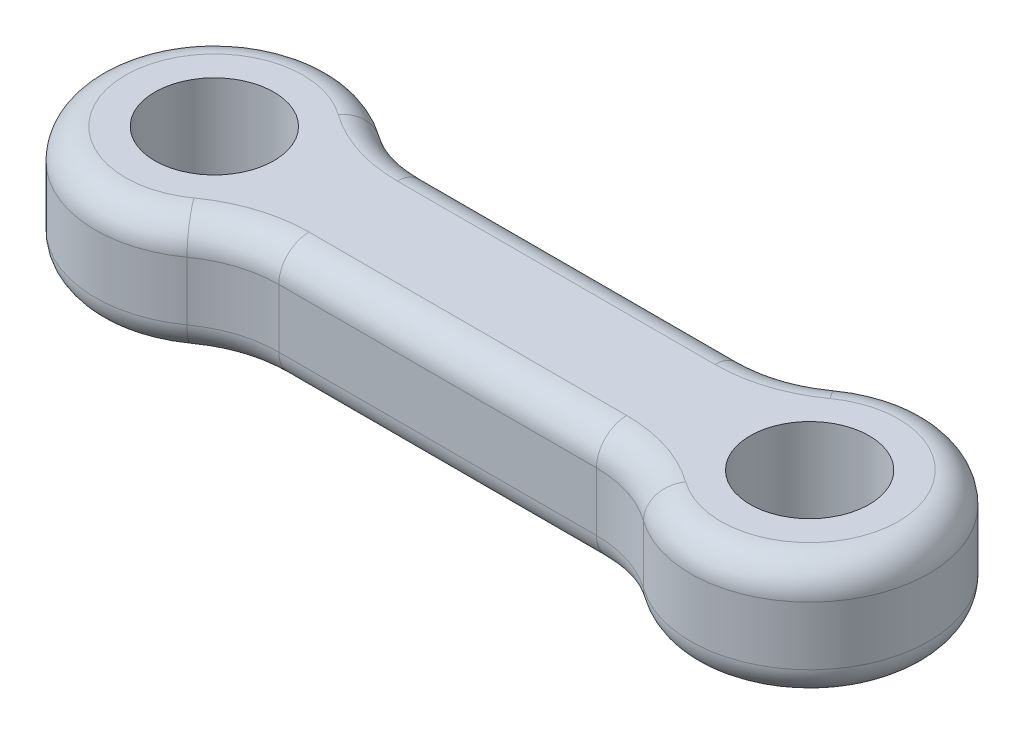
from build123d import *

# Parameters (mm, degrees)
SKETCH1_R           = 5
BOSS_EXTRUDE1_DEPTH = 10
FILLET1_R           = 2.54
SCALE1_SCALE        = 0.66


with BuildPart() as part:
    # Sketch1 → Boss-Extrude1 (new body)
    with BuildSketch(Plane(origin=(0, 0, 0), x_dir=(1, 0, 0), z_dir=(0, 1, 0))):
        with BuildLine():
            Line((-0.840776184, -6.25), (25.840776184, -6.25))
            ThreePointArc((25.840776184, -6.25), (28.902638362, -6.730283618), (31.670388092, -8.125))
            ThreePointArc((31.670388092, -8.125), (47.5, 0), (31.670388092, 8.125))
            ThreePointArc((31.670388092, 8.125), (28.902638362, 6.730283618), (25.840776184, 6.25))
            Line((25.840776184, 6.25), (-0.840776184, 6.25))
            ThreePointArc((-0.840776184, 6.25), (-3.902638362, 6.730283618), (-6.670388092, 8.125))
            ThreePointArc((-6.670388092, 8.125), (-22.5, 0), (-6.670388092, -8.125))
            ThreePointArc((-6.670388092, -8.125), (-3.902638362, -6.730283618), (-0.840776184, -6.25))
        make_face()
        with Locations((-12.5, 0)):
            Circle(SKETCH1_R, mode=Mode.SUBTRACT)
        with Locations((37.5, 0)):
            Circle(SKETCH1_R, mode=Mode.SUBTRACT)
    extrude(amount=BOSS_EXTRUDE1_DEPTH)

    # Fillet1
    fillet1_edges = [part.edges().sort_by_distance(p)[0] for p in [
        (-3.902638362, 10, 6.730283618),
        (-22.5, 0, 0),
        (-3.902638362, 0, -6.730283618),
        (12.5, 10, 6.25),
        (28.902638362, 10, 6.730283618),
        (47.5, 10, 0),
        (28.902638362, 10, -6.730283618),
        (12.5, 10, -6.25),
        (-3.902638362, 10, -6.730283618),
        (-22.5, 10, 0),
        (12.5, 0, -6.25),
        (28.902638362, 0, -6.730283618),
        (47.5, 0, 0),
        (28.902638362, 0, 6.730283618),
        (12.5, 0, 6.25),
        (-3.902638362, 0, 6.730283618),
    ]]
    fillet(fillet1_edges, radius=FILLET1_R)


with BuildPart() as part_1:
    # Scale1: scaled about (12.5, 5, 0)
    add(part.part.scale(SCALE1_SCALE).moved(Location((4.25, 1.7, 0))))


solid = part_1.part
